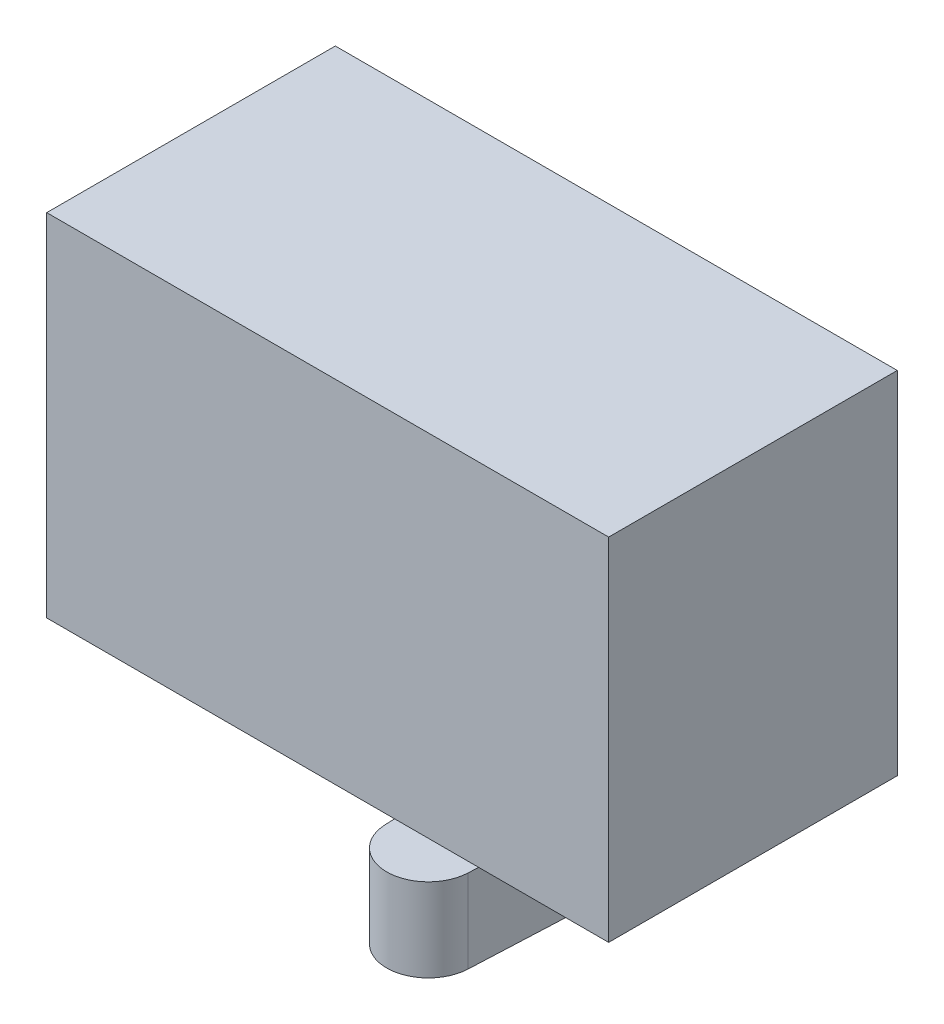
from build123d import *

# Parameters (mm, degrees)
SKETCH1_W           = 40.5
SKETCH1_H           = 25.3
BOSS_EXTRUDE1_DEPTH = 10.4
BOSS_EXTRUDE2_DEPTH = 6


with BuildPart() as part:
    # Sketch1 → Boss-Extrude1 (new, symmetric)
    with BuildSketch(Plane.XY):
        Rectangle(SKETCH1_W, SKETCH1_H)
    extrude(amount=BOSS_EXTRUDE1_DEPTH, both=True)


with BuildPart() as body_2:
    # Sketch3 → Boss-Extrude2 (new body)
    with BuildSketch(Plane.XZ.offset(12.65)):
        with BuildLine():
            Line((4.353617572, -0.159090909), (4.853100776, -11.136363636))
            ThreePointArc((4.853100776, -11.136363636), (7.85, -14), (10.846899224, -11.136363636))
            Line((10.846899224, -11.136363636), (11.346382428, -0.159090909))
            ThreePointArc((11.346382428, -0.159090909), (11.35, 0), (11.346382428, 0.159090909))
            Line((11.346382428, 0.159090909), (10.846899224, 11.136363636))
            ThreePointArc((10.846899224, 11.136363636), (7.85, 14), (4.853100776, 11.136363636))
            Line((4.853100776, 11.136363636), (4.353617572, 0.159090909))
            ThreePointArc((4.353617572, 0.159090909), (4.35, 0), (4.353617572, -0.159090909))
        make_face()
    extrude(amount=BOSS_EXTRUDE2_DEPTH)


solid = Compound([part.part, body_2.part])
